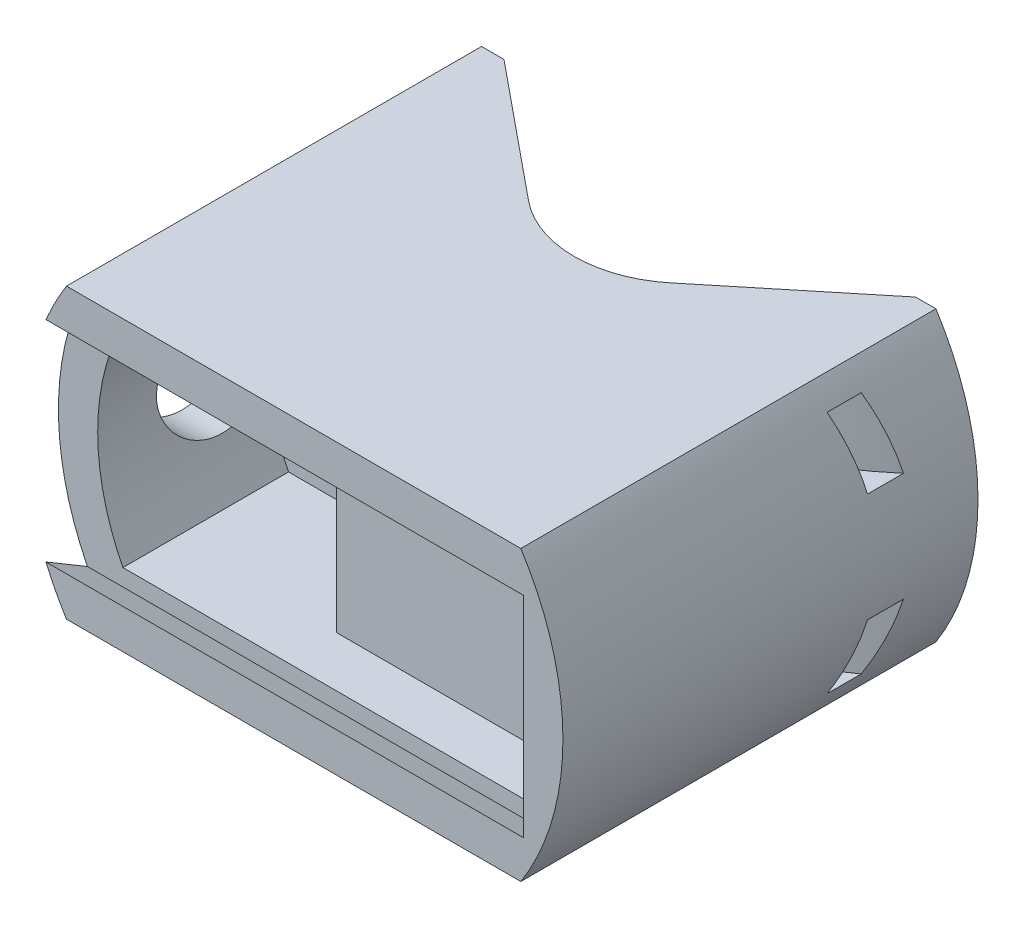
from build123d import *

# Parameters (mm, degrees)
BOSS_EXTRUDE2_DEPTH      = 7
BOSS_EXTRUDE2_DEPTH_BACK = 30
CUT_EXTRUDE1_DEPTH       = 25.712971991
FILLET1_R                = 10
CUT_EXTRUDE2_START       = -17.764514
CUT_EXTRUDE2_DEPTH       = 17.764514
BOSS_EXTRUDE3_DEPTH      = 10.764514
CUT_EXTRUDE3_REACH       = 60.021
SKETCH11_R               = 5.25
SKETCH12_W               = 2.5
SKETCH12_H               = 6
CUT_EXTRUDE10_START      = -44.470309
CUT_EXTRUDE10_DEPTH      = 44.470309


with BuildPart() as part:
    # Sketch7 → Boss-Extrude2 (new, two sides)
    with BuildSketch(Plane.XY) as boss_extrude2_sk:
        with BuildLine():
            Line((-20.343909144, -12.856485995), (20.159427524, -12.856485995))
            ThreePointArc((20.159427524, -12.856485995), (23.910076333, 0), (20.159427524, 12.856485995))
            Line((20.159427524, 12.856485995), (-20.343909144, 12.856485995))
            ThreePointArc((-20.343909144, 12.856485995), (-24.06023272, 0), (-20.343909144, -12.856485995))
        make_face()
    extrude(amount=BOSS_EXTRUDE2_DEPTH)
    extrude(boss_extrude2_sk.sketch, amount=-BOSS_EXTRUDE2_DEPTH_BACK)

    # Sketch8 → Cut-Extrude1 (cut)
    with BuildSketch(Plane(origin=(0, 12.856485995, 0), x_dir=(1, 0, 0), z_dir=(0, 1, 0))):
        Polygon((-18.343909144, 30), (0, 30), (0, 15), align=None)
    cut_extrude1 = extrude(amount=-CUT_EXTRUDE1_DEPTH, mode=Mode.SUBTRACT)

    # Mirror1: Cut-Extrude1 across plane
    add(cut_extrude1.mirror(Plane(origin=(0, 0, 0), x_dir=(0, 0, 1), z_dir=(1, 0, 0))), mode=Mode.SUBTRACT)

    # Fillet1
    fillet1_edges = [part.edges().sort_by_distance(p)[0] for p in [
        (0, 0, -15),
    ]]
    fillet(fillet1_edges, radius=FILLET1_R)

    # Sketch9 → Cut-Extrude2 (cut)
    with BuildSketch(Plane.XY.offset(7).offset(CUT_EXTRUDE2_START)):
        with BuildLine():
            Line((-18.312348097, -9.356485995), (18.139112044, -9.356485995))
            ThreePointArc((18.139112044, -9.356485995), (20.410076333, 0), (18.139112044, 9.356485995))
            Line((18.139112044, 9.356485995), (-18.312348097, 9.356485995))
            ThreePointArc((-18.312348097, 9.356485995), (-20.56023272, 0), (-18.312348097, -9.356485995))
        make_face()
    extrude(amount=CUT_EXTRUDE2_DEPTH, mode=Mode.SUBTRACT)


with BuildPart() as boss_extrude3_tool:
    # Sketch10 → Boss-Extrude3 (new body)
    with BuildSketch(Plane(origin=(0, 0, -10.764513537), x_dir=(-1, 0, 0), z_dir=(0, 0, -1))):
        with BuildLine():
            Line((3.288113076, 8.856485995), (3.288113076, -8.856485995))
            Line((3.288113076, -8.856485995), (-17.831819744, -8.856485995))
            ThreePointArc((-17.831819744, -8.856485995), (-19.910076333, 0), (-17.831819744, 8.856485995))
            Line((-17.831819744, 8.856485995), (3.288113076, 8.856485995))
        make_face()
    extrude(amount=-BOSS_EXTRUDE3_DEPTH)


with BuildPart() as part_1:
    add(part.part)


with BuildPart() as part_2:
    # Boss-Extrude3: joined with boss_extrude3_tool
    add(part_1.part.fuse(boss_extrude3_tool.part, tol=0.00001))

    # Cut-Extrude3: up to this face of the body (flat: up to its plane)
    cut_extrude3_end = Plane(part_2.part.faces().sort_by_distance((-3.288113076, 0, -5.382256537))[0])
    # Sketch11 → Cut-Extrude3 (cut, up to the picked face)
    with BuildSketch(Plane.ZY.offset(24.06023272), mode=Mode.PRIVATE) as cut_extrude3_sk1:
        with Locations((-6.485, 0.212445037)):
            Circle(SKETCH11_R)
    cut_extrude3_tool1 = split(extrude(cut_extrude3_sk1.sketch, amount=-CUT_EXTRUDE3_REACH, mode=Mode.PRIVATE), bisect_by=cut_extrude3_end, keep=Keep.BOTH, mode=Mode.PRIVATE)
    add(cut_extrude3_tool1.solids().sort_by(Axis((-24.060233, 0.212445, -6.485), (1, 0, 0)))[0], mode=Mode.SUBTRACT)

    # Sketch12 → Cut-Revolve1 (revolve, cut)
    with BuildSketch(Plane(origin=(0, 0, 0), x_dir=(0, 0, -1), z_dir=(1, 0, 0))):
        with Locations((14.035, 7.856485995)):
            Rectangle(SKETCH12_W, SKETCH12_H)
        with Locations((14.035, -7.856485995)):
            Rectangle(SKETCH12_W, SKETCH12_H)
    revolve(axis=Axis((0, -85.887973373, -51.567605329), (0, 1, 0)), mode=Mode.SUBTRACT)

    # Sketch14 → Cut-Extrude10 (cut)
    with BuildSketch(Plane.ZY.offset(24.06023272).offset(CUT_EXTRUDE10_START)):
        Polygon((7, 9.356485995), (4, 10.856485995), (4, -10.856485995), (7, -9.356485995), align=None)
    extrude(amount=CUT_EXTRUDE10_DEPTH, mode=Mode.SUBTRACT)


solid = part_2.part
